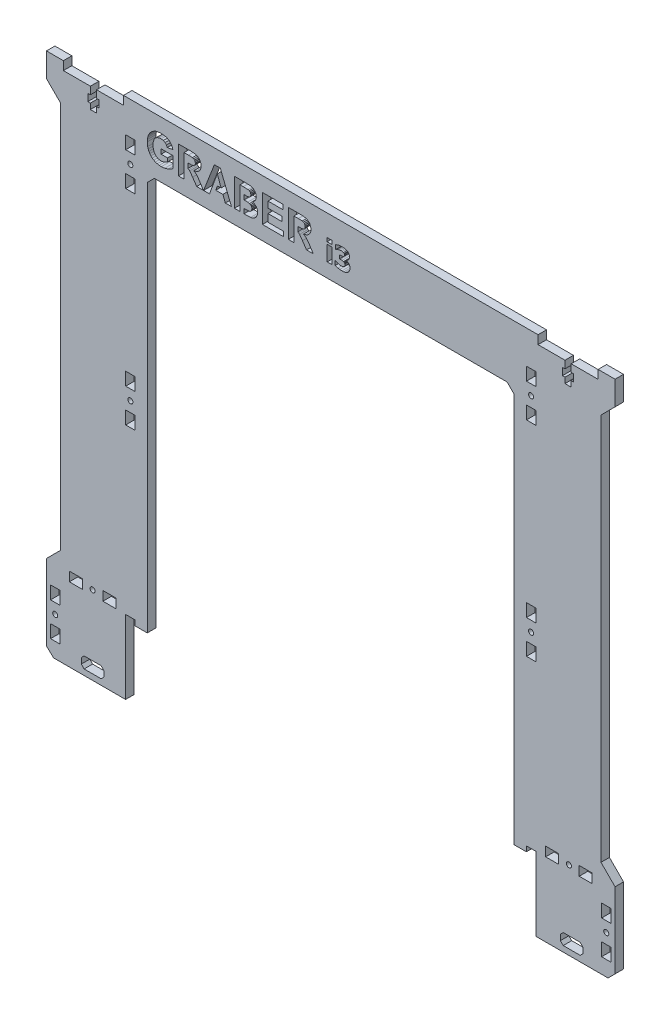
from build123d import *

# Parameters (mm, degrees)
MODEL_R                  = 1.8
MODEL_W                  = 9.199997699
MODEL_H                  = 6.599987016
MODEL_W_2                = 9.199995837
MODEL_W_3                = 6.600001918
MODEL_H_2                = 9.1999977
MODEL_W_4                = 6.600001917
MODEL_H_3                = 9.199995838
MODEL_H_4                = 9.199995837
MODEL_W_5                = 9.1999977
MODEL_W_6                = 3.544061303
MODEL_H_5                = 2.614942529
MODEL_W_7                = 3.352490421
MODEL_H_6                = 10.756704981
RESSALTO_EXTRUS_O1_DEPTH = 6


with BuildPart() as part:
    # Model → Ressalto-extrusão1 (new body)
    with BuildSketch(Plane.XY):
        Polygon((370.496069673, 89.643145773), (361.846072441, 89.643145773), (361.846072441, 366.133815093), (356.846074041, 371.133813493), (106.846154041, 371.133813493), (101.846155641, 366.133815093), (101.846155641, 89.643145773), (93.196158409, 89.643145773), (93.196158409, 93.333914917), (86.496160553, 93.333914917), (86.496160553, 41.143161293), (86.046164105, 41.133919093), (35.396172254, 41.133919093), (30.396173854, 45.94216914), (30.396173854, 99.633914413), (40.396173054, 109.633913613), (40.396173054, 384.133802853), (30.396173854, 394.133802053), (30.396173854, 411.133800693), (42.396170494, 411.133800693), (42.396170494, 405.033802645), (61.496152823, 405.033802645), (61.496152823, 399.733803824), (59.696154591, 399.733803824), (59.696154591, 394.633806059), (61.496152823, 394.633806059), (61.496152823, 390.683806237), (65.896157494, 390.683806237), (65.896157494, 394.633806059), (67.696155726, 394.633806059), (67.696155726, 399.733803824), (65.896157494, 399.733803824), (65.896157494, 405.033802645), (84.996153454, 405.033802645), (84.996153454, 411.133800693), (378.746066553, 411.133800693), (378.746066553, 405.033802645), (397.846062513, 405.033802645), (397.846062513, 399.733803824), (396.046064281, 399.733803824), (396.046064281, 394.633806059), (397.846062513, 394.633806059), (397.846062513, 390.683806237), (402.246067185, 390.683806237), (402.246067185, 394.633806059), (404.046065417, 394.633806059), (404.046065417, 399.733803824), (402.246067185, 399.733803824), (402.246067185, 405.033802645), (421.346049513, 405.033802645), (421.346049513, 411.133800693), (433.346046153, 411.133800693), (433.346046153, 394.133802053), (423.346046953, 384.133802853), (423.346046953, 109.633913613), (433.346046153, 99.633914413), (433.346046153, 46.133917493), (428.346047753, 41.133919093), (377.646063977, 41.133919093), (377.246067513, 41.143161293), (377.246067513, 93.333914917), (370.496069673, 93.333914917), align=None)
        with Locations((427.096055158, 68.383852909)):
            Circle(MODEL_R, mode=Mode.SUBTRACT)
        with Locations((400.64605348, 96.683839545)):
            Circle(MODEL_R, mode=Mode.SUBTRACT)
        with Locations((373.846068601, 226.143102093)):
            Circle(MODEL_R, mode=Mode.SUBTRACT)
        with Locations((373.846068601, 371.228025269)):
            Circle(MODEL_R, mode=Mode.SUBTRACT)
        with Locations((89.846159481, 371.228025269)):
            Circle(MODEL_R, mode=Mode.SUBTRACT)
        with Locations((89.846159481, 226.143102093)):
            Circle(MODEL_R, mode=Mode.SUBTRACT)
        with Locations((63.0961679, 96.683839545)):
            Circle(MODEL_R, mode=Mode.SUBTRACT)
        with Locations((36.596174846, 68.383852909)):
            Circle(MODEL_R, mode=Mode.SUBTRACT)
        with Locations((51.196173121, 96.683837666)):
            Rectangle(MODEL_W, MODEL_H, mode=Mode.SUBTRACT)
        with Locations((74.996163951, 96.683837666)):
            Rectangle(MODEL_W_2, MODEL_H, mode=Mode.SUBTRACT)
        with Locations((427.096054197, 56.48385813)):
            Rectangle(MODEL_W_3, MODEL_H_2, mode=Mode.SUBTRACT)
        with Locations((89.846158521, 359.328030489)):
            Rectangle(MODEL_W_4, MODEL_H_2, mode=Mode.SUBTRACT)
        with Locations((89.846158521, 383.128021319)):
            Rectangle(MODEL_W_4, MODEL_H_3, mode=Mode.SUBTRACT)
        Polygon((139.995049001, 395.285386417), (139.91372774, 394.22695248), (139.669763958, 393.264930347), (139.263157653, 392.399320018), (138.693908827, 391.630121494), (137.962855842, 390.975778771), (137.070837063, 390.454735847), (136.017852489, 390.066992721), (134.80390212, 389.812549395), (135.979287767, 389.024487691), (136.929991993, 388.162649998), (137.914230758, 386.915165089), (139.190220027, 384.970161735), (141.591293133, 381.133810293), (136.842802187, 381.133810293), (133.972245514, 385.412817671), (131.879690182, 388.303495069), (131.29954263, 388.806513177), (130.685860537, 389.121737859), (130.685860537, 392.481898825), (130.819998699, 392.481898825), (133.140588907, 392.542260998), (134.388073817, 392.723347517), (135.021876634, 393.051986014), (135.501420564, 393.555004123), (135.803231429, 394.218988026), (135.903835051, 395.030523908), (135.771373616, 395.927572869), (135.37398931, 396.633474948), (134.735156312, 397.131462876), (133.8783488, 397.404769381), (130.980964494, 397.471838462), (127.882372945, 397.471838462), (127.882372945, 381.133810293), (123.911883341, 381.133810293), (123.911883341, 400.798464888), (132.268690852, 400.798464888), (134.99001882, 400.666003452), (136.849509095, 400.268619146), (138.135558726, 399.532535981), (139.136564762, 398.383977966), (139.780427942, 396.931932359), align=None, mode=Mode.SUBTRACT)
        with Locations((89.846158521, 238.043098144)):
            Rectangle(MODEL_W_4, MODEL_H_4, mode=Mode.SUBTRACT)
        with Locations((89.846158521, 214.243107314)):
            Rectangle(MODEL_W_4, MODEL_H_2, mode=Mode.SUBTRACT)
        with Locations((36.596173885, 56.48385813)):
            Rectangle(MODEL_W_3, MODEL_H_2, mode=Mode.SUBTRACT)
        with Locations((36.596173885, 80.28384896)):
            Rectangle(MODEL_W_3, MODEL_H_4, mode=Mode.SUBTRACT)
        with Locations((388.746058701, 96.683837666)):
            Rectangle(MODEL_W_5, MODEL_H, mode=Mode.SUBTRACT)
        with Locations((412.54604953, 96.683837666)):
            Rectangle(MODEL_W_2, MODEL_H, mode=Mode.SUBTRACT)
        with Locations((427.096054197, 80.28384896)):
            Rectangle(MODEL_W_3, MODEL_H_4, mode=Mode.SUBTRACT)
        with Locations((373.84606764, 214.243107314)):
            Rectangle(MODEL_W_4, MODEL_H_2, mode=Mode.SUBTRACT)
        with Locations((373.84606764, 238.043098144)):
            Rectangle(MODEL_W_4, MODEL_H_4, mode=Mode.SUBTRACT)
        with Locations((373.84606764, 383.128021319)):
            Rectangle(MODEL_W_4, MODEL_H_3, mode=Mode.SUBTRACT)
        Polygon((104.720065768, 398.60195248), (105.737000711, 399.447861266), (106.90316436, 400.154601709), (107.906685487, 400.583005464), (109.025900779, 400.889008147), (111.611413857, 401.133810293), (113.342215333, 401.037817671), (114.872647928, 400.749839804), (116.202711644, 400.269876692), (117.332406479, 399.597928335), (118.27011607, 398.756630548), (119.024224052, 397.768619146), (119.594730423, 396.63389413), (119.981635185, 395.352455498), (116.037973213, 394.614695605), (115.439381664, 395.910805599), (114.475263622, 396.901751273), (113.185860537, 397.530523908), (111.611413857, 397.740114787), (110.376923582, 397.636996075), (109.275733106, 397.327639938), (108.307842428, 396.812046377), (107.47325155, 396.090215391), (106.801303193, 395.165500434), (106.321340081, 394.041254961), (106.033362214, 392.717478972), (105.937369591, 391.194172466), (106.034619759, 389.553075887), (106.326370262, 388.130792185), (106.8126211, 386.92732136), (107.493372274, 385.942663412), (108.331735789, 385.176818342), (109.290823649, 384.629786148), (110.370635856, 384.301566833), (111.571172408, 384.192160394), (112.820334045, 384.314561467), (114.072849135, 384.681764686), (115.23817442, 385.223347517), (116.22576664, 385.868887423), (116.22576664, 388.363857242), (111.678482938, 388.363857242), (111.678482938, 391.677069851), (120.236497693, 391.677069851), (120.236497693, 383.843401172), (118.70899937, 382.708256973), (116.621474219, 381.717311299), (114.238845111, 381.028176491), (111.826034917, 380.798464888), (110.332909498, 380.879366967), (108.938710973, 381.122073204), (107.643439343, 381.5265836), (106.447094608, 382.092898154), (105.371474219, 382.809698959), (104.438375628, 383.665668107), (103.647798834, 384.660805599), (102.999743837, 385.795111434), (102.495049001, 387.025409891), (102.13455269, 388.30852525), (101.846155641, 391.033206672), (101.926638538, 392.526332091), (102.168087231, 393.933944432), (102.570501718, 395.256043694), (103.133881999, 396.492629878), (103.852359531, 397.61687535), align=None, mode=Mode.SUBTRACT)
        Polygon((175.072178445, 381.267948456), (170.360441355, 381.135967025), (170.360441355, 384.447022902), (171.235827003, 384.447022902), (173.958831697, 384.567747248), (174.761983944, 384.844407208), (175.400816942, 385.352455498), (175.818321972, 386.081831755), (175.957490316, 387.022475619), (175.850179786, 387.840718409), (175.528248196, 388.524823036), (175.003432636, 389.058022232), (174.287470195, 389.423548724), (173.001420564, 389.63481633), (170.766343434, 389.705238865), (170.360441355, 389.705238865), (170.360441355, 392.982808156), (173.046692194, 393.045279106), (173.95715497, 393.281697617), (174.649643233, 393.749504458), (175.087268988, 394.425225451), (175.233144239, 395.285386417), (175.107389712, 396.112012842), (174.730126131, 396.76761311), (174.104706949, 397.225359589), (173.234485621, 397.458424646), (169.840790115, 397.525493727), (167.560441355, 397.525493727), (167.560441355, 381.133810293), (163.589951751, 381.133810293), (163.589951751, 400.798464888), (171.450448062, 400.798464888), (174.931333374, 400.603964552), (176.017852489, 400.303830414), (176.983647257, 399.79242867), (177.813627137, 399.073112775), (178.492701583, 398.149236182), (178.945417881, 397.06104034), (179.096323314, 395.848766698), (178.910206614, 394.524152346), (178.351856513, 393.313555431), (177.474928277, 392.304165759), (176.33307717, 391.583173137), (177.922614394, 390.875594331), (179.096323314, 389.799135578), (179.82066939, 388.427572869), (180.062118082, 386.834682191), (179.906182469, 385.511744566), (179.438375628, 384.225694935), (178.700615735, 383.085520555), (177.734820966, 382.200208684), (176.529254233, 381.588203318), align=None, mode=Mode.SUBTRACT)
        Polygon((209.139918217, 388.806513177), (208.526236124, 389.121737859), (208.522748532, 392.481898825), (208.660374286, 392.481898825), (210.980964494, 392.542260998), (212.228449404, 392.723347517), (212.862252221, 393.051986014), (213.341796151, 393.555004123), (213.643607016, 394.218988026), (213.744210638, 395.030523908), (213.611749202, 395.927572869), (213.214364897, 396.633474948), (212.575531899, 397.131462876), (211.718724387, 397.404769381), (208.821340081, 397.471838462), (205.722748532, 397.471838462), (205.722748532, 381.133810293), (201.752258927, 381.133810293), (201.752258927, 400.798464888), (210.109066439, 400.798464888), (212.830394407, 400.666003452), (214.689884682, 400.268619146), (215.975934313, 399.532535981), (216.976940349, 398.383977966), (217.620803528, 396.931932359), (217.835424588, 395.285386417), (217.754103327, 394.22695248), (217.510139544, 393.264930347), (217.10353324, 392.399320018), (216.534284414, 391.630121494), (215.803231429, 390.975778771), (214.91121265, 390.454735847), (213.858228076, 390.066992721), (212.644277707, 389.812549395), (213.819663354, 389.024487691), (214.770367579, 388.162649998), (215.754606345, 386.915165089), (217.030595614, 384.970161735), (219.43166872, 381.133810293), (214.683177774, 381.133810293), (211.8126211, 385.412817671), (209.720065768, 388.303495069), align=None, mode=Mode.SUBTRACT)
        Polygon((150.372417545, 385.600611098), (151.593074822, 388.913823707), (154.160038941, 388.913823707), (151.450448062, 396.210939737), (145.950783408, 381.133810293), (141.738845111, 381.133810293), (149.398134179, 400.798464888), (153.596658659, 400.798464888), (161.470568787, 381.133810293), (157.15131996, 381.133810293), (155.434351483, 385.600611098), align=None, mode=Mode.SUBTRACT)
        Polygon((198.371977237, 381.133810293), (183.41557214, 381.133810293), (183.41557214, 400.798464888), (197.996390383, 400.798464888), (197.996390383, 397.471838462), (187.386061744, 397.471838462), (187.386061744, 393.112348187), (197.25863049, 393.112348187), (197.25863049, 389.799135578), (187.386061744, 389.799135578), (187.386061744, 384.447022902), (198.371977237, 384.447022902), align=None, mode=Mode.SUBTRACT)
        with Locations((373.84606764, 359.328030489)):
            Rectangle(MODEL_W_4, MODEL_H_2, mode=Mode.SUBTRACT)
        Polygon((57.098185601, 53.170735619), (69.094150199, 53.170735619), (71.094150199, 51.170735619), (71.094150199, 47.170738179), (69.094150199, 45.170738179), (57.098185601, 45.170738179), (55.098185601, 47.170738179), (55.098185601, 51.170735619), align=None, mode=Mode.SUBTRACT)
        Polygon((410.594042321, 51.170735619), (410.594042321, 47.170738179), (408.594042321, 45.170738179), (396.598077723, 45.170738179), (394.598077723, 47.170738179), (394.598077723, 51.170735619), (396.598077723, 53.170735619), (408.594042321, 53.170735619), align=None, mode=Mode.SUBTRACT)
        with Locations((231.030473027, 394.730553589)):
            Rectangle(MODEL_W_6, MODEL_H_5, mode=Mode.SUBTRACT)
        with Locations((231.030473027, 386.512162784)):
            Rectangle(MODEL_W_7, MODEL_H_6, mode=Mode.SUBTRACT)
        Polygon((239.92894046, 395.693197267), (241.117877241, 395.638120638), (242.136794866, 395.472890753), (243.002455785, 395.202296883), (243.731622452, 394.831128301), (244.368595632, 394.319873512), (244.823576475, 393.686492286), (245.096564981, 392.947747075), (245.187561149, 392.120400332), (245.011555402, 390.97935627), (244.483538161, 389.989174278), (243.668164597, 389.236061251), (242.630089885, 388.806224086), (242.630089885, 388.67212447), (243.621469195, 388.41350378), (244.564955785, 387.819634048), (244.95887341, 387.392191519), (245.278557318, 386.85699037), (245.490482605, 386.211635964), (245.561124368, 385.453733665), (245.464141609, 384.455170447), (245.173193333, 383.547603397), (244.695463448, 382.750189604), (244.038135862, 382.082086155), (243.215578391, 381.549279642), (242.261315938, 381.157756653), (241.129850421, 380.917095734), (239.775683755, 380.836875427), (238.227551571, 380.906319872), (236.916488352, 381.114653205), (234.97683318, 381.737258569), (234.97683318, 384.831128301), (235.321660766, 384.831128301), (236.175348505, 384.366568914), (237.165530498, 383.969059335), (238.177264214, 383.69607083), (239.095607126, 383.605074661), (240.221086053, 383.69607083), (240.780233563, 383.840946309), (241.241200996, 384.093580408), (241.763231647, 384.682660868), (241.910501762, 385.105314125), (241.959591801, 385.674040178), (241.890147356, 386.233187688), (241.681814023, 386.646262401), (241.358538161, 386.939605313), (240.94426613, 387.13955742), (239.842733563, 387.321549757), (238.712465364, 387.340706845), (238.099438544, 387.340706845), (238.099438544, 389.850285389), (238.664572643, 389.850285389), (239.861890651, 389.907756653), (240.791009425, 390.137641711), (241.389668429, 390.645304546), (241.55130636, 391.028446309), (241.60518567, 391.5265306), (241.554898314, 391.918053588), (241.404036245, 392.230553588), (240.905951954, 392.656798799), (240.101354253, 392.886683857), (239.31591364, 392.944155121), (238.243116705, 392.819634048), (237.179898314, 392.503542094), (236.336986437, 392.106032516), (235.68564544, 391.737258569), (235.388710574, 391.737258569), (235.388710574, 394.792814125), (237.376258467, 395.401051673), (238.639428965, 395.620160868), align=None, mode=Mode.SUBTRACT)
    extrude(amount=RESSALTO_EXTRUS_O1_DEPTH)


solid = part.part
